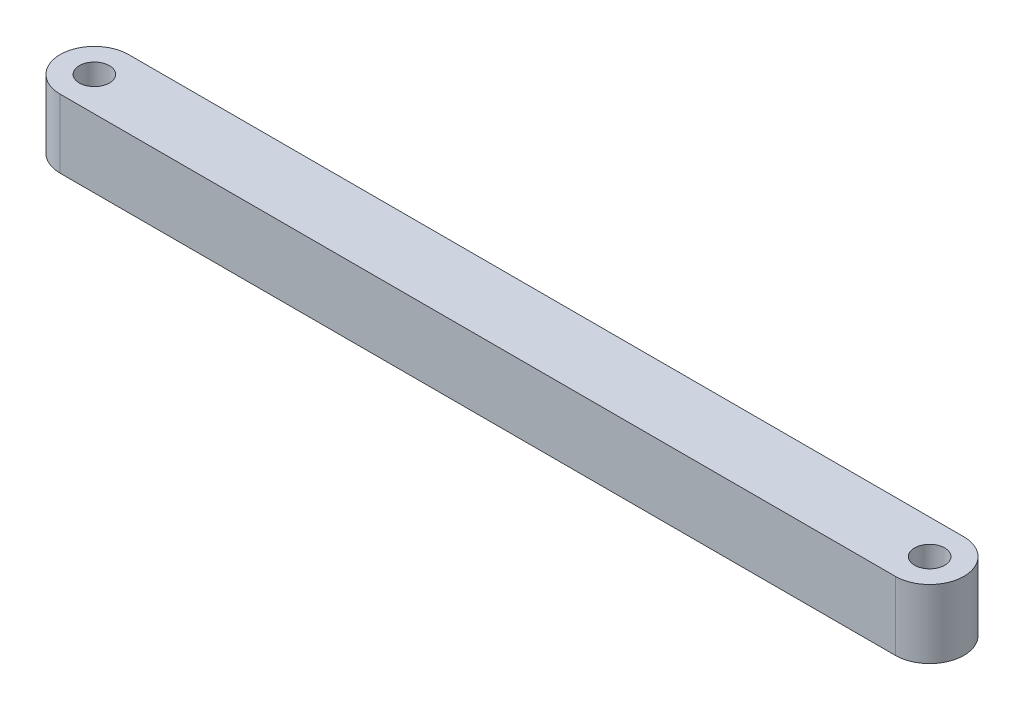
from build123d import *

# Parameters (mm, degrees)
SKETCH1_R           = 1.1
BOSS_EXTRUDE1_DEPTH = 5


with BuildPart() as part:
    # Sketch1 → Boss-Extrude1 (new body)
    with BuildSketch(Plane(origin=(0, 0, 0), x_dir=(1, 0, 0), z_dir=(0, 1, 0))):
        with BuildLine():
            Line((-58.7, 2.5), (2.26469372, 2.5))
            ThreePointArc((2.26469372, 2.5), (4.76469372, 0), (2.26469372, -2.5))
            Line((2.26469372, -2.5), (-58.7, -2.5))
            ThreePointArc((-58.7, -2.5), (-61.2, 0), (-58.7, 2.5))
        make_face()
        with Locations((2.26469372, 0)):
            Circle(SKETCH1_R, mode=Mode.SUBTRACT)
        with Locations((-58.7, 0)):
            Circle(SKETCH1_R, mode=Mode.SUBTRACT)
    extrude(amount=BOSS_EXTRUDE1_DEPTH)


solid = part.part
